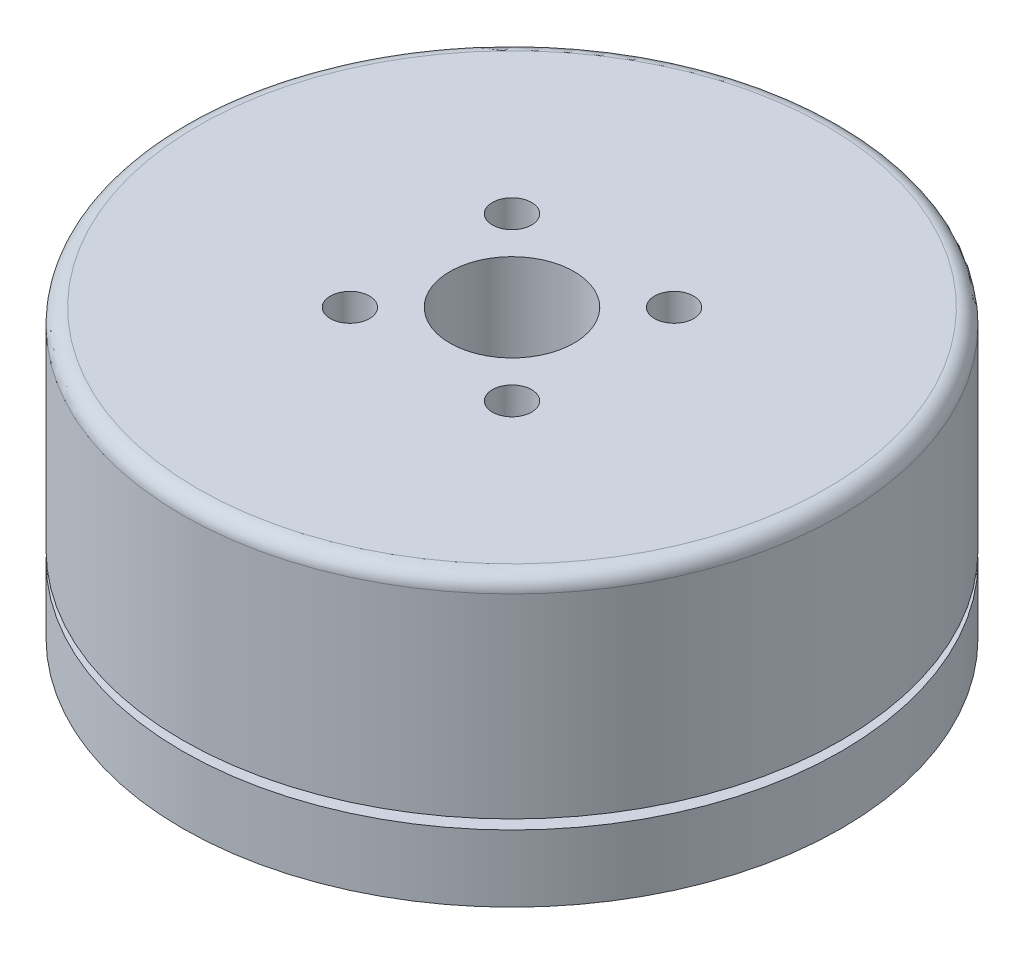
from build123d import *

# Parameters (mm, degrees)
CUT_EXTRUDE_START        = -3.5
SKETCH_4_R               = 17.25
SKETCH_4_R_2             = 16.25
CUT_EXTRUDE_1_DEPTH      = 0.5
HOLE_WIZARD_M2_5_2_D     = 2.05
HOLE_WIZARD_M2_5_2_DEPTH = 3.5
HOLE_WIZARD_M2_5_2_TIP   = 0.615882135
SKETCH_9_W               = 5.8
SKETCH_9_H               = 1.5
EXTRUDE_1_DEPTH          = 4
HOLE_WIZARD_M2_5_1_D     = 2.05
HOLE_WIZARD_M2_5_1_DEPTH = 3.5
HOLE_WIZARD_M2_5_1_TIP   = 0.615882135
FILLET_1_R               = 0.8
SKETCH_14_R              = 4
CUT_EXTRUDE_1_2_DEPTH    = 1.3


with BuildPart() as part:
    # 草图1 → 旋转1 (revolve)
    with BuildSketch(Plane.XY):
        Polygon((-6, 0), (-6, 1.62), (-17.25, 1.62), (-17.25, 16.62), (-3.25, 16.62), (-3.25, 0), align=None)
    revolve(axis=Axis((0, 44.719290515, 0), (0, -1, 0)))

    # 草图4 → Cut-Extrude 1 (cut)
    with BuildSketch(Plane.XZ.offset(-1.62).offset(CUT_EXTRUDE_START)):
        Circle(SKETCH_4_R)
        Circle(SKETCH_4_R_2, mode=Mode.SUBTRACT)
    extrude(amount=-CUT_EXTRUDE_1_DEPTH, mode=Mode.SUBTRACT)

    # M2.5 螺纹孔2
    with Locations(Plane(origin=(0, 1.62, 0), x_dir=(-1, 0, 0), z_dir=(0, -1, 0))):
        with Locations((-6.717514421, 6.717514421), (-6.717514421, -6.717514421), (6.717514421, -6.717514421), (6.717514421, 6.717514421)):
            Hole(HOLE_WIZARD_M2_5_2_D / 2, depth=HOLE_WIZARD_M2_5_2_DEPTH)
            with Locations((0, 0, -(HOLE_WIZARD_M2_5_2_DEPTH + HOLE_WIZARD_M2_5_2_TIP / 2))):  # 118° drill point
                Cone(0, HOLE_WIZARD_M2_5_2_D / 2, HOLE_WIZARD_M2_5_2_TIP, mode=Mode.SUBTRACT)

    # 草图9 → 凸台-拉伸1 (add)
    with BuildSketch(Plane.XZ.offset(-1.62)):
        with Locations((0, -14.5)):
            Rectangle(SKETCH_9_W, SKETCH_9_H)
    extrude(amount=EXTRUDE_1_DEPTH)

    # M2.5 螺纹孔1
    with Locations(Plane(origin=(0, 16.62, 0), x_dir=(1, 0, 0), z_dir=(0, 1, 0))):
        with Locations((-4.242640687, 4.242640687), (4.242640687, 4.242640687), (4.242640687, -4.242640687), (-4.242640687, -4.242640687)):
            Hole(HOLE_WIZARD_M2_5_1_D / 2, depth=HOLE_WIZARD_M2_5_1_DEPTH)
            with Locations((0, 0, -(HOLE_WIZARD_M2_5_1_DEPTH + HOLE_WIZARD_M2_5_1_TIP / 2))):  # 118° drill point
                Cone(0, HOLE_WIZARD_M2_5_1_D / 2, HOLE_WIZARD_M2_5_1_TIP, mode=Mode.SUBTRACT)

    # 圆角1
    fillet_1_edges = [part.edges().sort_by_distance(p)[0] for p in [
        (17.25, 16.62, 0),
    ]]
    fillet(fillet_1_edges, radius=FILLET_1_R)

    # 草图14 → Cut-Extrude 1 2 (cut)
    with BuildSketch(Plane.XZ):
        Circle(SKETCH_14_R)
    extrude(amount=-CUT_EXTRUDE_1_2_DEPTH, mode=Mode.SUBTRACT)


solid = part.part
